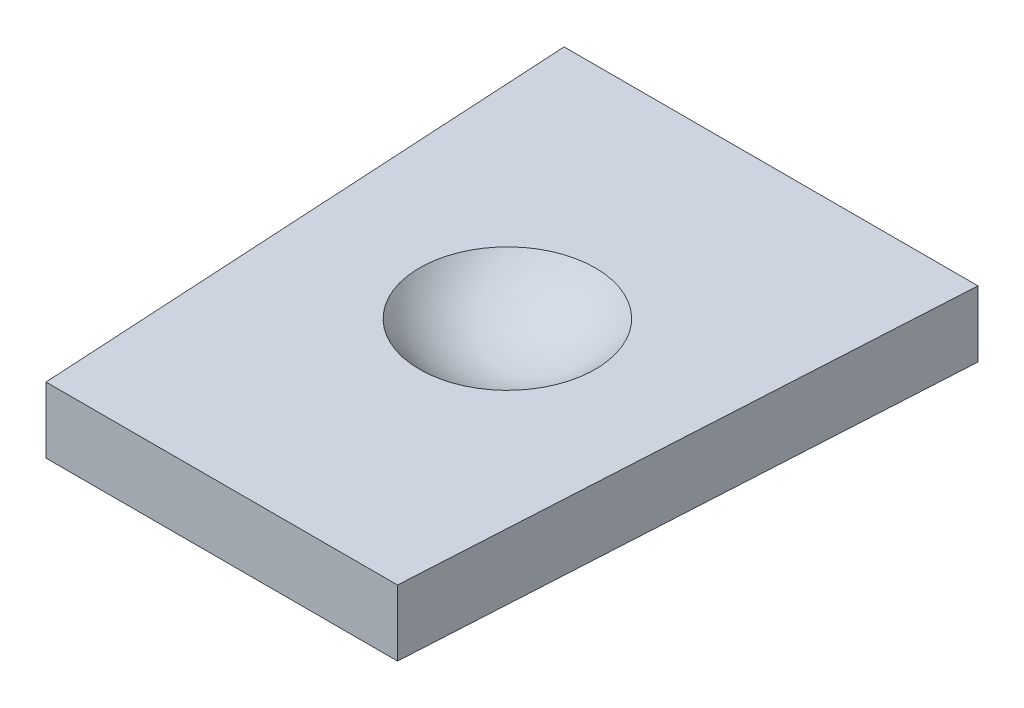
from build123d import *

# Parameters (mm, degrees)
BOSS_EXTRUDE1_DEPTH = 3


with BuildPart() as part:
    # Sketch1 → Boss-Extrude1 (new body)
    with BuildSketch(Plane(origin=(0, 0, 0), x_dir=(1, 0, 0), z_dir=(0, 1, 0))):
        Polygon((-9.419602878, 89.5), (-8, 64.5), (0, 64.5), (0, 89.5), align=None)
    boss_extrude1 = extrude(amount=BOSS_EXTRUDE1_DEPTH)

    # Mirror1: Boss-Extrude1 across plane
    add(boss_extrude1.mirror(Plane(origin=(0, 0, 0), x_dir=(0, 0, 1), z_dir=(1, 0, 0))))

    # Sketch2 → Cut-Revolve1 (revolve, cut)
    with BuildSketch(Plane(origin=(0, 0, 0), x_dir=(0, 0, -1), z_dir=(1, 0, 0))):
        with BuildLine():
            Line((72.5, 6), (77.5, 6))
            Line((77.5, 6), (77.5, 1))
            ThreePointArc((77.5, 1), (73.964466094, 2.464466094), (72.5, 6))
        make_face()
    revolve(axis=Axis((0, 6, -77.5), (0, -1, 0)), mode=Mode.SUBTRACT)


solid = part.part
